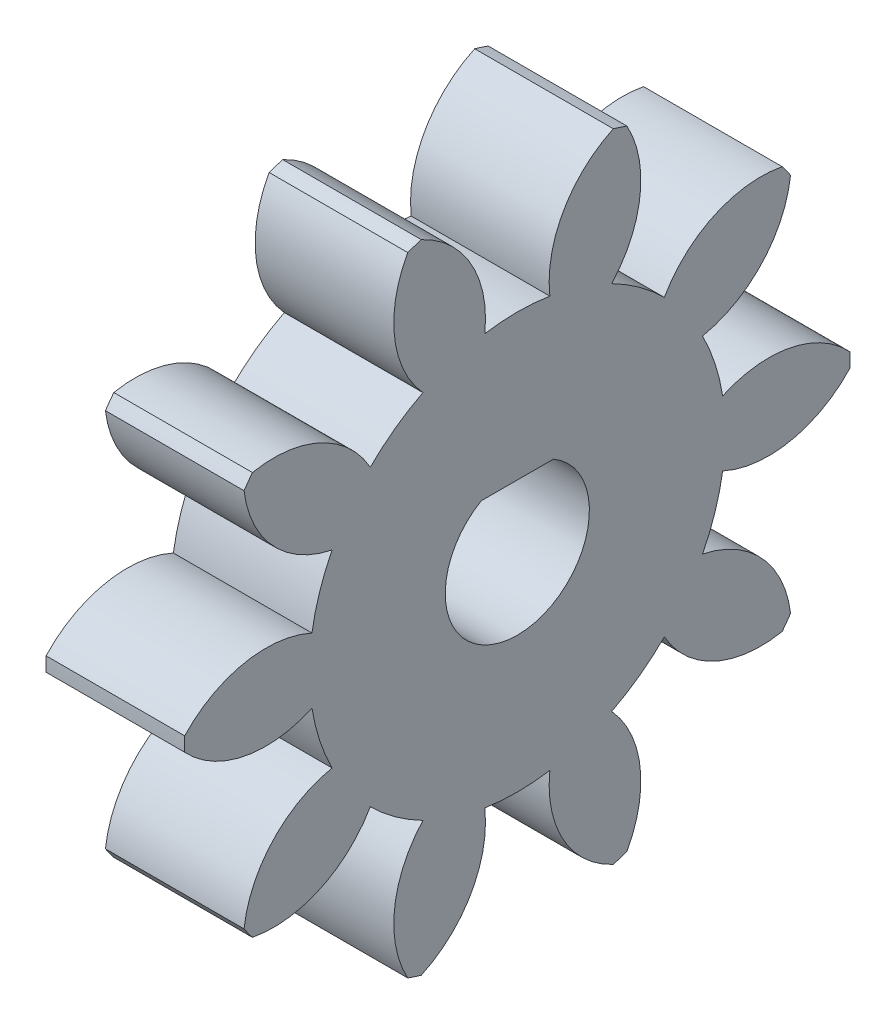
from build123d import *

# Parameters (mm, degrees)
BASPROSKE_W        = 5
BASPROSKE_H        = 12
TOOTHCUT_DEPTH     = 18.691806013
TEETHCUTS_COUNT    = 10
TEETHCUTS_ANGLE    = 324
BORSKE_R           = 0.5
BORE_DEPTH         = 50.0000508
SKETCH2_R          = 0.5
CUT_EXTRUDE1_DEPTH = 10


with BuildPart() as part:
    # BasProSke → Base-Revolve (revolve)
    with BuildSketch(Plane(origin=(0, 0, 0), x_dir=(1, 0, 0), z_dir=(0, 1, 0)), mode=Mode.PRIVATE) as base_revolve_sk:
        with Locations((2.5, 6)):
            Rectangle(BASPROSKE_W, BASPROSKE_H)
    revolve(base_revolve_sk.sketch.rotate(Axis((-10, 0, 0), (1, 0, 0)), 180), axis=Axis((-10, 0, 0), (1, 0, 0)))

    # TooCutSke → ToothCut (cut, through all)
    with BuildSketch(Plane(origin=(0, 0, 0), x_dir=(0, 0, -1), z_dir=(1, 0, 0))):
        with BuildLine():
            ThreePointArc((1.173662691, 7.406586048), (0, 7.499), (-1.173662691, 7.406586048))
            ThreePointArc((-1.173662691, 7.406586048), (-1.668191438, 9.834565786), (-3.497907776, 11.50542856))
            ThreePointArc((-3.497907776, 11.50542856), (0, 12.0254), (3.497907776, 11.50542856))
            ThreePointArc((3.497907776, 11.50542856), (1.668191438, 9.834565786), (1.173662691, 7.406586048))
        make_face()
    toothcut = extrude(amount=TOOTHCUT_DEPTH, mode=Mode.SUBTRACT)

    # TeethCuts: ToothCut ×10 about axis
    teethcuts_axis = Axis((-10, 0, 0), (1, 0, 0))
    for i in range(1, TEETHCUTS_COUNT):
        add(toothcut.rotate(teethcuts_axis, i * TEETHCUTS_ANGLE / (TEETHCUTS_COUNT - 1)), mode=Mode.SUBTRACT)

    # BorSke → Bore (cut, symmetric)
    with BuildSketch(Plane(origin=(0, 0, 0), x_dir=(0, 0, -1), z_dir=(1, 0, 0))):
        with Locations(Location((0, 0, 0), (0, 0, 180))):
            Circle(BORSKE_R)
    extrude(amount=BORE_DEPTH, both=True, mode=Mode.SUBTRACT)

    # Sketch2 → Cut-Extrude1 (cut)
    with BuildSketch(Plane.ZY):
        with BuildLine():
            Line((1.302881422, 2.25), (-1.302881422, 2.25))
            ThreePointArc((-1.302881422, 2.25), (-1.29855849, -2.252497691), (2.6, 0))
            ThreePointArc((2.6, 0), (2.252497691, 1.29855849), (1.302881422, 2.25))
        make_face()
        Circle(SKETCH2_R, mode=Mode.SUBTRACT)
    extrude(amount=-CUT_EXTRUDE1_DEPTH, mode=Mode.SUBTRACT)


solid = part.part
